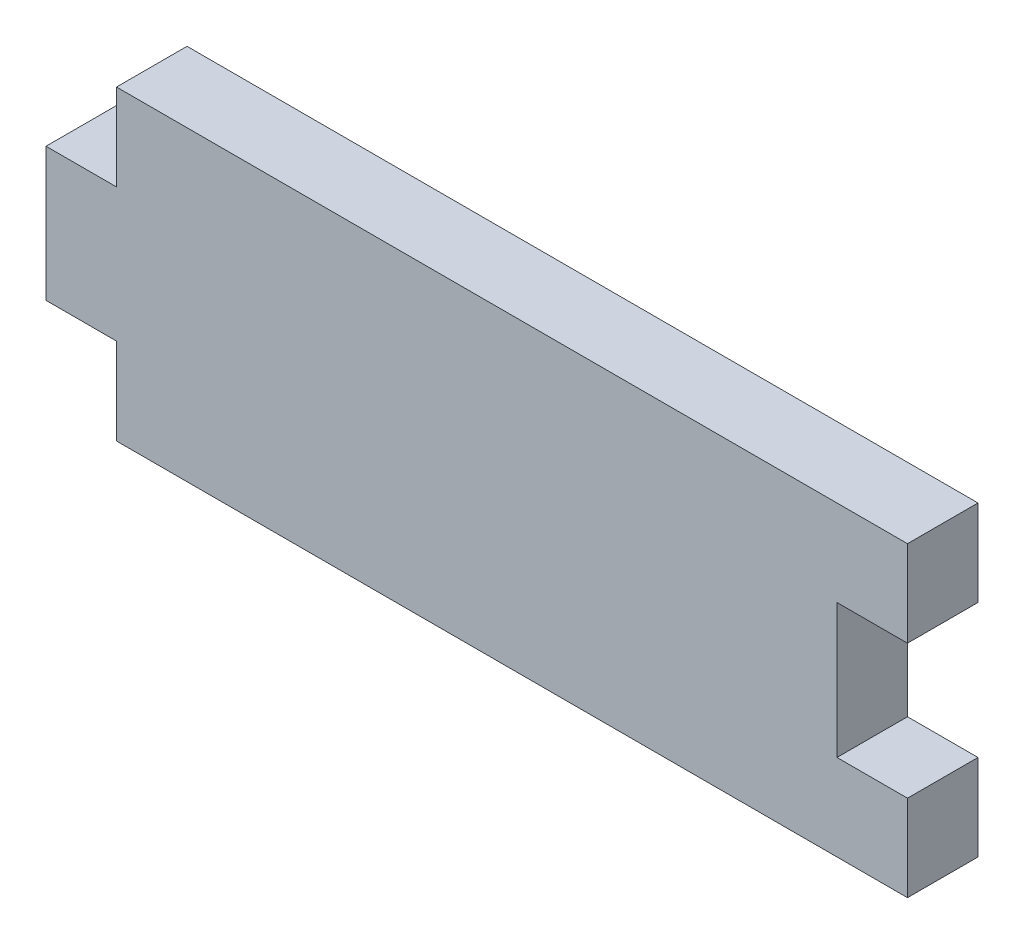
from build123d import *

# Parameters (mm, degrees)
BOSS_EXTRUDE1_DEPTH = 4.6


with BuildPart() as part:
    # Sketch1 → Boss-Extrude1 (new body)
    with BuildSketch(Plane.XY):
        Polygon((-25.8, -10), (25.8, -10), (25.8, -4.377357027), (21.2, -4.377357027), (21.2, 4.377357027), (25.8, 4.377357027), (25.8, 10), (-25.8, 10), (-25.8, 4.355117679), (-30.4, 4.355117679), (-30.4, -4.355117679), (-25.8, -4.355117679), align=None)
    extrude(amount=BOSS_EXTRUDE1_DEPTH)


solid = part.part
